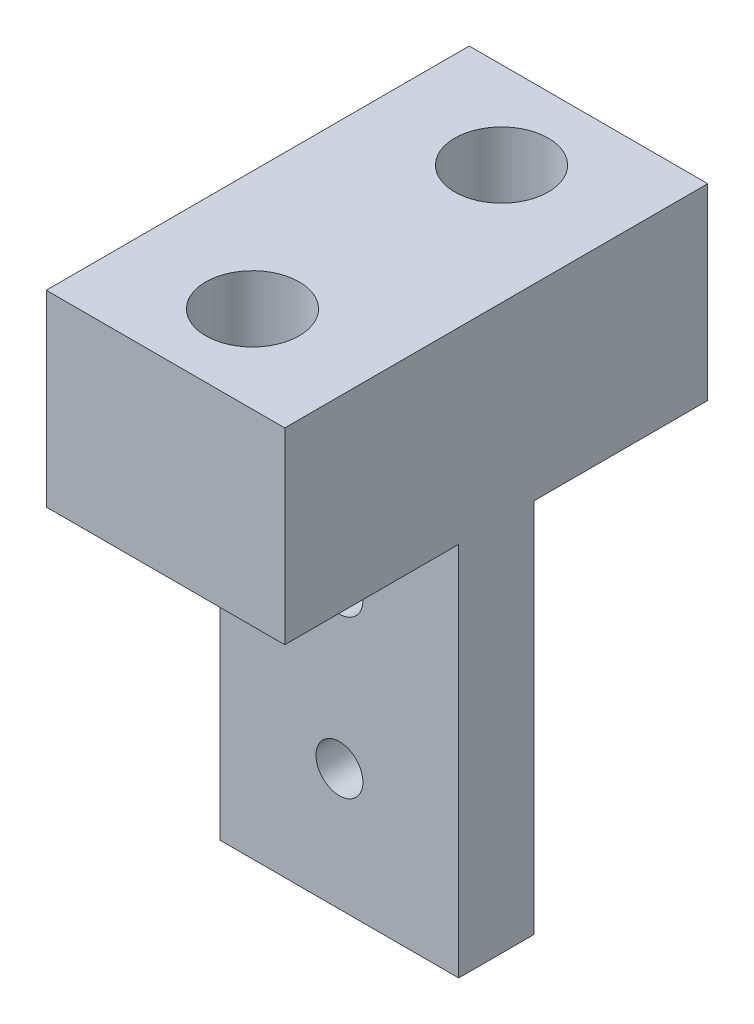
from build123d import *

# Parameters (mm, degrees)
ESBO_O1_W                = 30
ESBO_O1_H                = 22.5248
RESSALTO_EXTRUS_O1_DEPTH = 12.7
ESBO_O2_W                = 9.2624
ESBO_O2_H                = 20
CORTE_EXTRUS_O1_DEPTH    = 13.7
ESBO_O3_W                = 9.2624
ESBO_O3_H                = 20
CORTE_EXTRUS_O2_DEPTH    = 13.7
FURO1_D                  = 4.9784
FURO1_DEPTH              = 10
FURO1_CBORE_D            = 7.9375
FURO1_CBORE_DEPTH        = 4.1656
ESBO_O8_R                = 1.25
CORTE_EXTRUS_O3_DEPTH    = 10


with BuildPart() as part:
    # Esboço1 → Ressalto-extrusão1 (new body)
    with BuildSketch(Plane(origin=(0, 0, 0), x_dir=(0, -1, 0), z_dir=(-1, 0, 0))):
        with Locations((15, 11.2624)):
            Rectangle(ESBO_O1_W, ESBO_O1_H)
    extrude(amount=-RESSALTO_EXTRUS_O1_DEPTH)

    # Esboço2 → Corte-extrusão1 (cut, through all)
    with BuildSketch(Plane(origin=(12.7, 0, 0), x_dir=(0, 0, -1), z_dir=(1, 0, 0))):
        with Locations((-4.6312, -20)):
            Rectangle(ESBO_O2_W, ESBO_O2_H)
    extrude(amount=-CORTE_EXTRUS_O1_DEPTH, mode=Mode.SUBTRACT)

    # Esboço3 → Corte-extrusão2 (cut, through all)
    with BuildSketch(Plane(origin=(12.7, 0, 0), x_dir=(0, 0, -1), z_dir=(1, 0, 0))):
        with Locations((-17.8936, -20)):
            Rectangle(ESBO_O3_W, ESBO_O3_H)
    extrude(amount=-CORTE_EXTRUS_O2_DEPTH, mode=Mode.SUBTRACT)

    # Furo1
    with Locations(Plane(origin=(0, -10, 0), x_dir=(-1, 0, 0), z_dir=(0, -1, 0))):
        with Locations((-6.35, -4.6312), (-6.35, -17.8936)):
            CounterBoreHole(FURO1_D / 2, FURO1_CBORE_D / 2, FURO1_CBORE_DEPTH, depth=FURO1_DEPTH)

    # Esboço8 → Corte-extrusão3 (cut)
    with BuildSketch(Plane.XY.offset(13.2624)):
        with Locations((6.35, -15.143672471)):
            Circle(ESBO_O8_R)
        with Locations((6.35, -23.520600125)):
            Circle(ESBO_O8_R)
    extrude(amount=-CORTE_EXTRUS_O3_DEPTH, mode=Mode.SUBTRACT)


solid = part.part
